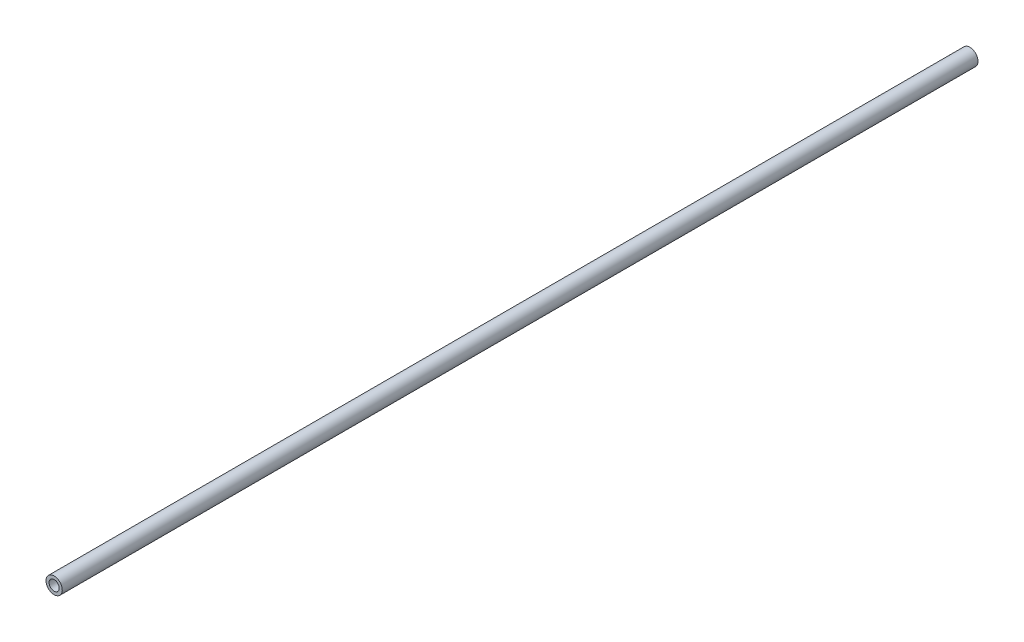
from build123d import *

# Parameters (mm, degrees)
CROQUIS1_R                    = 4
SALIENTE_EXTRUIR1_DEPTH       = 450
TALADRO_ROSCADO_M6X1_01_D     = 5
TALADRO_ROSCADO_M6X1_01_DEPTH = 17
TALADRO_ROSCADO_M6X1_01_TIP   = 1.502151548
TALADRO_ROSCADO_M6X1_02_D     = 5
TALADRO_ROSCADO_M6X1_02_DEPTH = 17
TALADRO_ROSCADO_M6X1_02_TIP   = 1.502151548


with BuildPart() as part:
    # Croquis1 → Saliente-Extruir1 (new body)
    with BuildSketch(Plane.XY):
        Circle(CROQUIS1_R)
    extrude(amount=SALIENTE_EXTRUIR1_DEPTH)

    # Taladro roscado M6x1.01
    with Locations(Plane.XY.offset(450)):
        with Locations((0, 0)):
            Hole(TALADRO_ROSCADO_M6X1_01_D / 2, depth=TALADRO_ROSCADO_M6X1_01_DEPTH)
            with Locations((0, 0, -(TALADRO_ROSCADO_M6X1_01_DEPTH + TALADRO_ROSCADO_M6X1_01_TIP / 2))):  # 118° drill point
                Cone(0, TALADRO_ROSCADO_M6X1_01_D / 2, TALADRO_ROSCADO_M6X1_01_TIP, mode=Mode.SUBTRACT)

    # Taladro roscado M6x1.02
    with Locations(Plane(origin=(0, 0, 0), x_dir=(-1, 0, 0), z_dir=(0, 0, -1))):
        with Locations((0, 0)):
            Hole(TALADRO_ROSCADO_M6X1_02_D / 2, depth=TALADRO_ROSCADO_M6X1_02_DEPTH)
            with Locations((0, 0, -(TALADRO_ROSCADO_M6X1_02_DEPTH + TALADRO_ROSCADO_M6X1_02_TIP / 2))):  # 118° drill point
                Cone(0, TALADRO_ROSCADO_M6X1_02_D / 2, TALADRO_ROSCADO_M6X1_02_TIP, mode=Mode.SUBTRACT)


solid = part.part
